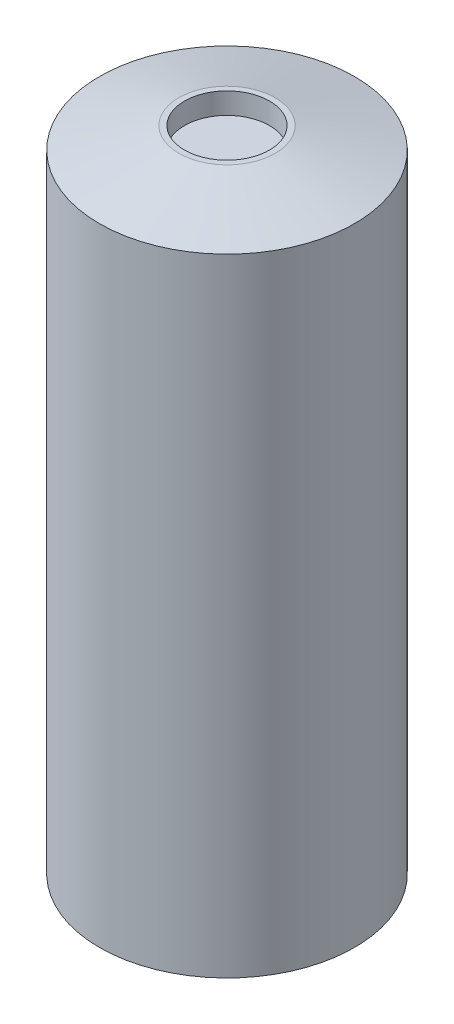
from build123d import *

# Parameters (mm, degrees)
ESQUISSE1_R             = 6
EXTRUSION1_DEPTH        = 30.5
CHANFREIN1_SIZE         = 1
CHANFREIN1_SIZE2        = 3.732050808
ESQUISSE2_R             = 2
ENL_V_MAT_EXTRU_1_DEPTH = 1


with BuildPart() as part:
    # Esquisse1 → Extrusion1 (new body)
    with BuildSketch(Plane(origin=(0, 0, 0), x_dir=(1, 0, 0), z_dir=(0, 1, 0))):
        Circle(ESQUISSE1_R)
    extrude(amount=EXTRUSION1_DEPTH)

    # Chanfrein1
    chanfrein1_edges = [part.edges().sort_by_distance(p)[0] for p in [
        (-6, 30.5, 0),
    ]]
    chanfrein1_side = [part.faces().sort_by_distance(p)[0] for p in [
        (-6, 15.25, 0),
    ]]
    chamfer(chanfrein1_edges, length=CHANFREIN1_SIZE, length2=CHANFREIN1_SIZE2, reference=chanfrein1_side[0])

    # Esquisse2 → Enlèv. mat.-Extru.1 (cut)
    with BuildSketch(Plane(origin=(0, 30.5, 0), x_dir=(1, 0, 0), z_dir=(0, 1, 0))):
        Circle(ESQUISSE2_R)
    extrude(amount=-ENL_V_MAT_EXTRU_1_DEPTH, mode=Mode.SUBTRACT)


solid = part.part
